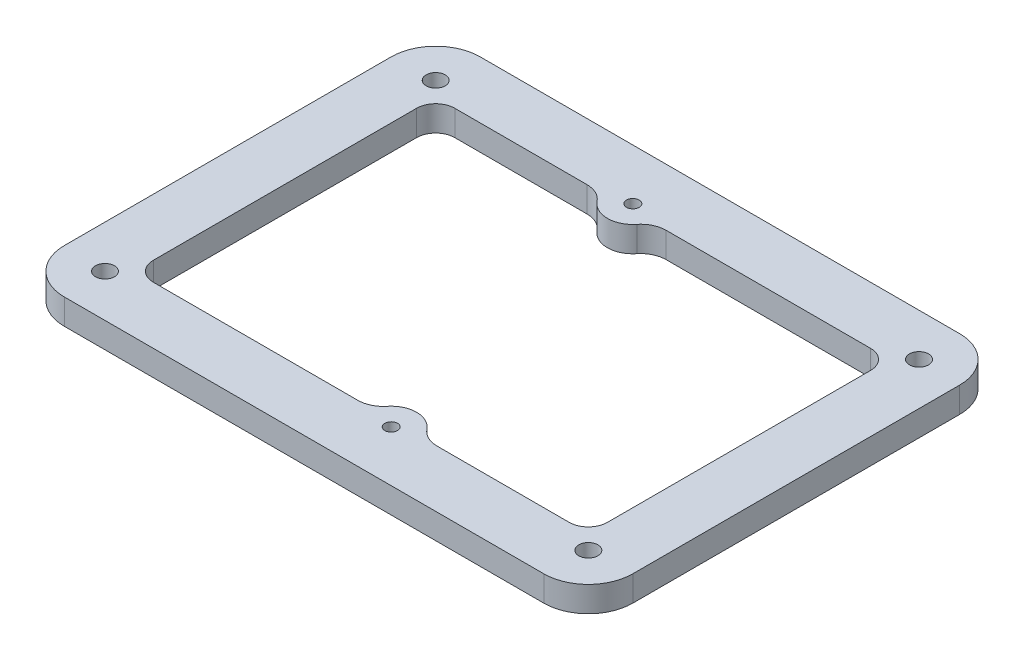
from build123d import *

# Parameters (mm, degrees)
SKETCH_2_R      = 1.5
SKETCH_2_R_2    = 1
EXTRUDE_1_DEPTH = 4
FILLET_1_R      = 7


with BuildPart() as part:
    # 草圖2 → 填料-伸長1 (new body)
    with BuildSketch(Plane(origin=(0, 0, 0), x_dir=(-1, 0, 0), z_dir=(0, 1, 0))):
        Polygon((32.696699141, -32.696699141), (-32.696699141, -32.696699141), (-44.696699141, -32.696699141), (-44.696699141, -20.696699141), (-44.696699141, 20.696699141), (-44.696699141, 32.696699141), (-32.696699141, 32.696699141), (32.696699141, 32.696699141), (44.696699141, 32.696699141), (44.696699141, 20.696699141), (44.696699141, -20.696699141), (44.696699141, -32.696699141), align=None)
        with Locations((38, 26)):
            Circle(SKETCH_2_R, mode=Mode.SUBTRACT)
        with Locations((38, -26)):
            Circle(SKETCH_2_R, mode=Mode.SUBTRACT)
        with Locations((-38, 26)):
            Circle(SKETCH_2_R, mode=Mode.SUBTRACT)
        with Locations((-38, -26)):
            Circle(SKETCH_2_R, mode=Mode.SUBTRACT)
        with Locations((5.700000775, -24.699999821)):
            Circle(SKETCH_2_R_2, mode=Mode.SUBTRACT)
        with Locations((-5.699999225, 24.700000179)):
            Circle(SKETCH_2_R_2, mode=Mode.SUBTRACT)
        with BuildLine():
            Line((32.696699141, -23.696699141), (11.942354682, -23.696699141))
            ThreePointArc((11.942354682, -23.696699141), (10.211256961, -23.302708109), (8.821177729, -22.198349481))
            ThreePointArc((8.821177729, -22.198349481), (5.700000775, -20.699999821), (2.578823821, -22.198349481))
            ThreePointArc((2.578823821, -22.198349481), (1.188744589, -23.302708109), (-0.542353133, -23.696699141))
            Line((-0.542353133, -23.696699141), (-32.696699141, -23.696699141))
            ThreePointArc((-32.696699141, -23.696699141), (-34.818019485, -22.818019485), (-35.696699141, -20.696699141))
            Line((-35.696699141, -20.696699141), (-35.696699141, 20.696699141))
            ThreePointArc((-35.696699141, 20.696699141), (-34.818019485, 22.818019485), (-32.696699141, 23.696699141))
            Line((-32.696699141, 23.696699141), (-11.942352846, 23.696699141))
            ThreePointArc((-11.942352846, 23.696699141), (-10.211255228, 23.302708159), (-8.821176036, 22.19834966))
            ThreePointArc((-8.821176036, 22.19834966), (-5.699999225, 20.700000179), (-2.578822415, 22.19834966))
            ThreePointArc((-2.578822415, 22.19834966), (-1.188743222, 23.302708159), (0.542354396, 23.696699141))
            Line((0.542354396, 23.696699141), (32.696699141, 23.696699141))
            ThreePointArc((32.696699141, 23.696699141), (34.818019485, 22.818019485), (35.696699141, 20.696699141))
            Line((35.696699141, 20.696699141), (35.696699141, -20.696699141))
            ThreePointArc((35.696699141, -20.696699141), (34.818019485, -22.818019485), (32.696699141, -23.696699141))
        make_face(mode=Mode.SUBTRACT)
    extrude(amount=EXTRUDE_1_DEPTH)

    # 圓角1
    fillet_1_edges = [part.edges().sort_by_distance(p)[0] for p in [
        (44.696699141, 2, -32.696699141),
        (44.696699141, 2, 32.696699141),
        (-44.696699141, 2, 32.696699141),
        (-44.696699141, 2, -32.696699141),
    ]]
    fillet(fillet_1_edges, radius=FILLET_1_R)


solid = part.part
